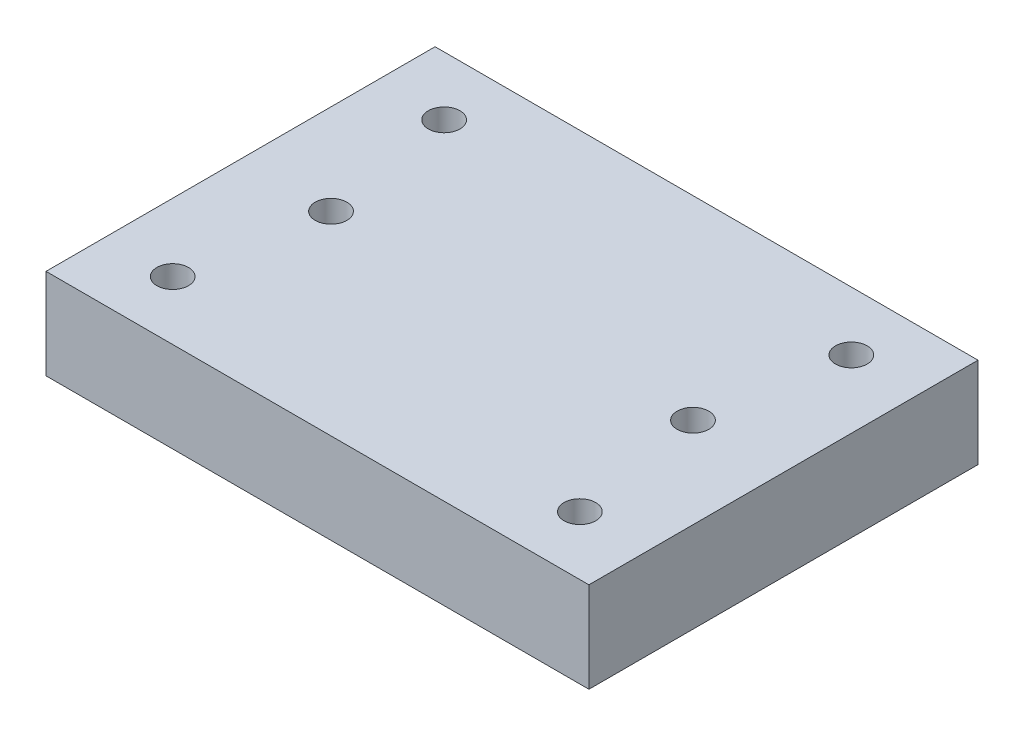
from build123d import *

# Parameters (mm, degrees)
SKETCH_2_W          = 60
SKETCH_2_H          = 43
EXTRUDE_1_DEPTH     = 10
SKETCH_3_R          = 1.75
CUT_EXTRUDE_1_DEPTH = 11
SKETCH_4_R          = 1.75
CUT_EXTRUDE_2_DEPTH = 11


with BuildPart() as part:
    # 草图2 → 凸台-拉伸1 (new body)
    with BuildSketch(Plane(origin=(0, 0, 0), x_dir=(1, 0, 0), z_dir=(0, 1, 0))):
        Rectangle(SKETCH_2_W, SKETCH_2_H)
    extrude(amount=EXTRUDE_1_DEPTH)

    # 草图3 → 切除-拉伸1 (cut, through all)
    with BuildSketch(Plane(origin=(0, 10, 0), x_dir=(1, 0, 0), z_dir=(0, 1, 0))):
        with Locations((-22.5, 15)):
            Circle(SKETCH_3_R)
        with Locations((22.5, 15)):
            Circle(SKETCH_3_R)
        with Locations((22.5, -15)):
            Circle(SKETCH_3_R)
        with Locations((-22.5, -15)):
            Circle(SKETCH_3_R)
    extrude(amount=-CUT_EXTRUDE_1_DEPTH, mode=Mode.SUBTRACT)

    # 草图4 → 切除-拉伸2 (cut, through all)
    with BuildSketch(Plane(origin=(0, 10, 0), x_dir=(1, 0, 0), z_dir=(0, 1, 0))):
        with Locations((-20, 0)):
            Circle(SKETCH_4_R)
        with Locations((20, 0)):
            Circle(SKETCH_4_R)
    extrude(amount=-CUT_EXTRUDE_2_DEPTH, mode=Mode.SUBTRACT)


solid = part.part
